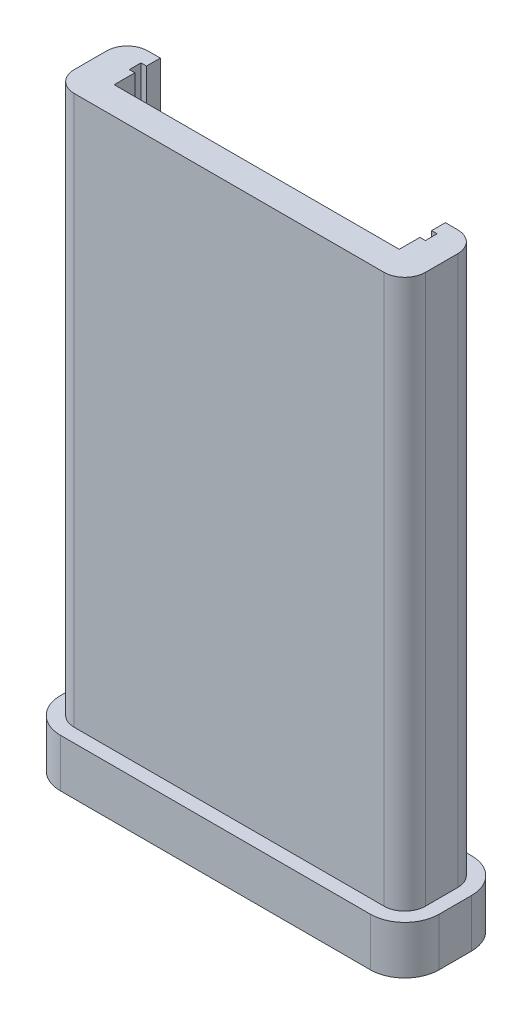
from build123d import *

# Parameters (mm, degrees)
SKETCH2_W               = 88.9
SKETCH2_H               = 152.4
BOSS_EXTRUDE1_DEPTH     = 5.9944
SKETCH4_R               = 2.7305
CUT_EXTRUDE2_DEPTH      = 1
CUT_EXTRUDE2_DEPTH_BACK = 6.9944
BOSS_EXTRUDE2_DEPTH     = 101.6
FILLET1_R               = 3.81
SKETCH7_W               = 2.54
SKETCH7_H               = 152.4
CUT_EXTRUDE3_DEPTH      = 102.6
CUT_EXTRUDE3_DEPTH_BACK = 6.9944
SKETCH11_W              = 86.36
SKETCH11_H              = 152.4
CUT_EXTRUDE4_DEPTH      = 6.35
BOSS_EXTRUDE3_DEPTH     = 8.89
SKETCH13_R              = 2.7305
CUT_EXTRUDE5_DEPTH      = 6.35


with BuildPart() as part:
    # Sketch2 → Boss-Extrude1 (new body)
    with BuildSketch(Plane(origin=(0, 0, 0), x_dir=(1, 0, 0), z_dir=(0, 1, 0))):
        with Locations((44.45, 76.2)):
            Rectangle(SKETCH2_W, SKETCH2_H)
    extrude(amount=BOSS_EXTRUDE1_DEPTH)

    # Sketch4 → Cut-Extrude2 (cut, two sides)
    with BuildSketch(Plane(origin=(0, 5.9944, 0), x_dir=(1, 0, 0), z_dir=(0, 1, 0))) as cut_extrude2_sk:
        with Locations((45.72, 109.871331367)):
            Circle(SKETCH4_R)
        with Locations((45.72, 33.671331367)):
            Circle(SKETCH4_R)
    extrude(amount=CUT_EXTRUDE2_DEPTH, mode=Mode.SUBTRACT)
    extrude(cut_extrude2_sk.sketch, amount=-CUT_EXTRUDE2_DEPTH_BACK, mode=Mode.SUBTRACT)

    # Sketch5 → Boss-Extrude2 (add)
    with BuildSketch(Plane(origin=(0, 5.9944, 0), x_dir=(1, 0, 0), z_dir=(0, 1, 0))):
        Polygon((18.161, 16.129), (12.065, 16.129), (12.065, 2.54), (76.835, 2.54), (76.835, 16.129), (70.739, 16.129), (70.739, 13.589), (71.755, 13.589), (71.755, 11.43), (70.739, 11.43), (70.739, 7.62), (18.161, 7.62), (18.161, 11.43), (17.145, 11.43), (17.145, 13.589), (18.161, 13.589), align=None)
    extrude(amount=BOSS_EXTRUDE2_DEPTH)

    # Fillet1
    fillet1_edges = [part.edges().sort_by_distance(p)[0] for p in [
        (12.065, 56.7944, -16.129),
        (12.065, 56.7944, -2.54),
        (76.835, 56.7944, -2.54),
        (76.835, 56.7944, -16.129),
    ]]
    fillet(fillet1_edges, radius=FILLET1_R)

    # Sketch7 → Cut-Extrude3 (cut, two sides)
    with BuildSketch(Plane(origin=(0, 5.9944, 0), x_dir=(1, 0, 0), z_dir=(0, 1, 0))) as cut_extrude3_sk:
        with Locations((1.27, 76.2)):
            Rectangle(SKETCH7_W, SKETCH7_H)
    extrude(amount=CUT_EXTRUDE3_DEPTH, mode=Mode.SUBTRACT)
    extrude(cut_extrude3_sk.sketch, amount=-CUT_EXTRUDE3_DEPTH_BACK, mode=Mode.SUBTRACT)

    # Sketch11 → Cut-Extrude4 (cut)
    with BuildSketch(Plane.XZ):
        with Locations((45.72, -76.2)):
            Rectangle(SKETCH11_W, SKETCH11_H)
    extrude(amount=-CUT_EXTRUDE4_DEPTH, mode=Mode.SUBTRACT)

    # Sketch12 → Boss-Extrude3 (add)
    with BuildSketch(Plane.XZ.offset(-6.35)):
        with BuildLine():
            Line((9.525, -6.35), (9.525, -12.319))
            ThreePointArc((9.525, -12.319), (11.384871939, -16.809128061), (15.875, -18.669))
            Line((15.875, -18.669), (18.161, -18.669))
            Line((18.161, -18.669), (70.739, -18.669))
            Line((70.739, -18.669), (73.025, -18.669))
            ThreePointArc((73.025, -18.669), (77.515128061, -16.809128061), (79.375, -12.319))
            Line((79.375, -12.319), (79.375, -6.35))
            ThreePointArc((79.375, -6.35), (77.515128061, -1.859871939), (73.025, 0))
            Line((73.025, 0), (15.875, 0))
            ThreePointArc((15.875, 0), (11.384871939, -1.859871939), (9.525, -6.35))
        make_face()
        with BuildLine():
            Line((18.161, -16.129), (70.739, -16.129))
            Line((70.739, -16.129), (73.025, -16.129))
            ThreePointArc((73.025, -16.129), (75.719076836, -15.013076836), (76.835, -12.319))
            Line((76.835, -12.319), (76.835, -6.35))
            ThreePointArc((76.835, -6.35), (75.719076836, -3.655923164), (73.025, -2.54))
            Line((73.025, -2.54), (15.875, -2.54))
            ThreePointArc((15.875, -2.54), (13.180923164, -3.655923164), (12.065, -6.35))
            Line((12.065, -6.35), (12.065, -12.319))
            ThreePointArc((12.065, -12.319), (13.180923164, -15.013076836), (15.875, -16.129))
            Line((15.875, -16.129), (18.161, -16.129))
        make_face(mode=Mode.SUBTRACT)
        with BuildLine():
            Line((70.739, -11.43), (71.755, -11.43))
            Line((71.755, -11.43), (71.755, -13.589))
            Line((71.755, -13.589), (70.739, -13.589))
            Line((70.739, -13.589), (70.739, -16.129))
            Line((70.739, -16.129), (73.025, -16.129))
            ThreePointArc((73.025, -16.129), (75.719076836, -15.013076836), (76.835, -12.319))
            Line((76.835, -12.319), (76.835, -6.35))
            ThreePointArc((76.835, -6.35), (75.719076836, -3.655923164), (73.025, -2.54))
            Line((73.025, -2.54), (15.875, -2.54))
            ThreePointArc((15.875, -2.54), (13.180923164, -3.655923164), (12.065, -6.35))
            Line((12.065, -6.35), (12.065, -12.319))
            ThreePointArc((12.065, -12.319), (13.180923164, -15.013076836), (15.875, -16.129))
            Line((15.875, -16.129), (18.161, -16.129))
            Line((18.161, -16.129), (18.161, -13.589))
            Line((18.161, -13.589), (17.145, -13.589))
            Line((17.145, -13.589), (17.145, -11.43))
            Line((17.145, -11.43), (18.161, -11.43))
            Line((18.161, -11.43), (18.161, -7.62))
            Line((18.161, -7.62), (70.739, -7.62))
            Line((70.739, -7.62), (70.739, -11.43))
        make_face()
        Polygon((18.161, -16.129), (70.739, -16.129), (70.739, -13.589), (71.755, -13.589), (71.755, -11.43), (70.739, -11.43), (70.739, -7.62), (18.161, -7.62), (18.161, -11.43), (17.145, -11.43), (17.145, -13.589), (18.161, -13.589), align=None)
    extrude(amount=BOSS_EXTRUDE3_DEPTH)

    # Sketch13 → Cut-Extrude5 (cut)
    with BuildSketch(Plane.XZ.offset(2.54)):
        with Locations((19.05, -9.3345)):
            Circle(SKETCH13_R)
        with Locations((69.85, -9.3345)):
            Circle(SKETCH13_R)
    extrude(amount=-CUT_EXTRUDE5_DEPTH, mode=Mode.SUBTRACT)


solid = part.part
